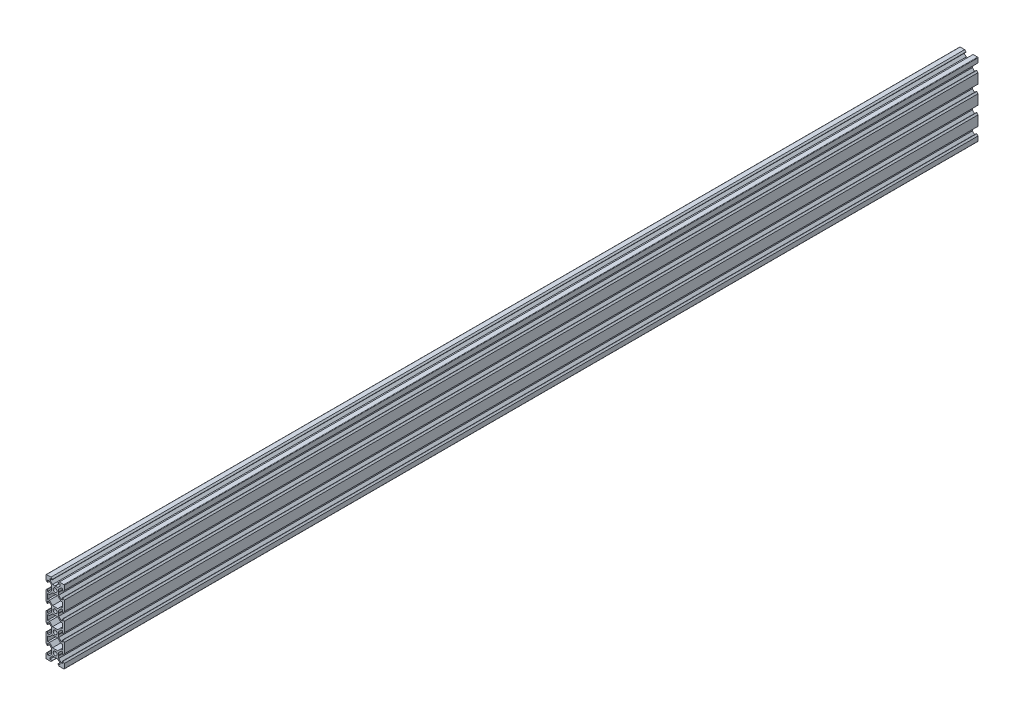
from build123d import *

# Parameters (mm, degrees)
SKETCH1_R           = 2.1
BOSS_EXTRUDE1_DEPTH = 1000


with BuildPart() as part:
    # Sketch1 → Boss-Extrude1 (new body)
    with BuildSketch(Plane.XY):
        with BuildLine():
            Line((4.58, -40), (9.5, -40))
            ThreePointArc((9.5, -40), (9.853553391, -39.853553391), (10, -39.5))
            Line((10, -39.5), (10, -34.58))
            Line((10, -34.58), (8.545, -33.125))
            Line((8.545, -33.125), (8.2, -33.125))
            Line((8.2, -33.125), (8.2, -35.5))
            Line((8.2, -35.5), (6.560660172, -35.5))
            Line((6.560660172, -35.5), (3.9, -32.839339828))
            Line((3.9, -32.839339828), (3.9, -30.21))
            Line((3.9, -30.21), (3.69, -30))
            Line((3.69, -30), (3.9, -29.79))
            Line((3.9, -29.79), (3.9, -27.160660172))
            Line((3.9, -27.160660172), (6.560660172, -24.5))
            Line((6.560660172, -24.5), (8.2, -24.5))
            Line((8.2, -24.5), (8.2, -26.875))
            Line((8.2, -26.875), (8.545, -26.875))
            Line((8.545, -26.875), (10, -25.42))
            Line((10, -25.42), (10, -14.58))
            Line((10, -14.58), (8.545, -13.125))
            Line((8.545, -13.125), (8.2, -13.125))
            Line((8.2, -13.125), (8.2, -15.5))
            Line((8.2, -15.5), (6.560660172, -15.5))
            Line((6.560660172, -15.5), (3.9, -12.839339828))
            Line((3.9, -12.839339828), (3.9, -10.21))
            Line((3.9, -10.21), (3.69, -10))
            Line((3.69, -10), (3.9, -9.79))
            Line((3.9, -9.79), (3.9, -7.160660172))
            Line((3.9, -7.160660172), (6.560660172, -4.5))
            Line((6.560660172, -4.5), (8.2, -4.5))
            Line((8.2, -4.5), (8.2, -6.875))
            Line((8.2, -6.875), (8.545, -6.875))
            Line((8.545, -6.875), (10, -5.42))
            Line((10, -5.42), (10, 5.42))
            Line((10, 5.42), (8.545, 6.875))
            Line((8.545, 6.875), (8.2, 6.875))
            Line((8.2, 6.875), (8.2, 4.5))
            Line((8.2, 4.5), (6.560660172, 4.5))
            Line((6.560660172, 4.5), (3.9, 7.160660172))
            Line((3.9, 7.160660172), (3.9, 9.79))
            Line((3.9, 9.79), (3.69, 10))
            Line((3.69, 10), (3.9, 10.21))
            Line((3.9, 10.21), (3.9, 12.839339828))
            Line((3.9, 12.839339828), (6.560660172, 15.5))
            Line((6.560660172, 15.5), (8.2, 15.5))
            Line((8.2, 15.5), (8.2, 13.125))
            Line((8.2, 13.125), (8.545, 13.125))
            Line((8.545, 13.125), (10, 14.58))
            Line((10, 14.58), (10, 25.42))
            Line((10, 25.42), (8.545, 26.875))
            Line((8.545, 26.875), (8.2, 26.875))
            Line((8.2, 26.875), (8.2, 24.5))
            Line((8.2, 24.5), (6.560660172, 24.5))
            Line((6.560660172, 24.5), (3.9, 27.160660172))
            Line((3.9, 27.160660172), (3.9, 29.79))
            Line((3.9, 29.79), (3.69, 30))
            Line((3.69, 30), (3.9, 30.21))
            Line((3.9, 30.21), (3.9, 32.839339828))
            Line((3.9, 32.839339828), (6.560660172, 35.5))
            Line((6.560660172, 35.5), (8.2, 35.5))
            Line((8.2, 35.5), (8.2, 33.125))
            Line((8.2, 33.125), (8.545, 33.125))
            Line((8.545, 33.125), (10, 34.58))
            Line((10, 34.58), (10, 39.5))
            ThreePointArc((10, 39.5), (9.853553391, 39.853553391), (9.5, 40))
            Line((9.5, 40), (4.58, 40))
            Line((4.58, 40), (3.125, 38.545))
            Line((3.125, 38.545), (3.125, 38.2))
            Line((3.125, 38.2), (5.5, 38.2))
            Line((5.5, 38.2), (5.5, 36.560660172))
            Line((5.5, 36.560660172), (2.839339828, 33.9))
            Line((2.839339828, 33.9), (0.21, 33.9))
            Line((0.21, 33.9), (0, 33.69))
            Line((0, 33.69), (-0.21, 33.9))
            Line((-0.21, 33.9), (-2.839339828, 33.9))
            Line((-2.839339828, 33.9), (-5.5, 36.560660172))
            Line((-5.5, 36.560660172), (-5.5, 38.2))
            Line((-5.5, 38.2), (-3.125, 38.2))
            Line((-3.125, 38.2), (-3.125, 38.545))
            Line((-3.125, 38.545), (-4.58, 40))
            Line((-4.58, 40), (-9.5, 40))
            ThreePointArc((-9.5, 40), (-9.853553391, 39.853553391), (-10, 39.5))
            Line((-10, 39.5), (-10, 34.58))
            Line((-10, 34.58), (-8.545, 33.125))
            Line((-8.545, 33.125), (-8.2, 33.125))
            Line((-8.2, 33.125), (-8.2, 35.5))
            Line((-8.2, 35.5), (-6.560660172, 35.5))
            Line((-6.560660172, 35.5), (-3.9, 32.839339828))
            Line((-3.9, 32.839339828), (-3.9, 30.21))
            Line((-3.9, 30.21), (-3.69, 30))
            Line((-3.69, 30), (-3.9, 29.79))
            Line((-3.9, 29.79), (-3.9, 27.160660172))
            Line((-3.9, 27.160660172), (-6.560660172, 24.5))
            Line((-6.560660172, 24.5), (-8.2, 24.5))
            Line((-8.2, 24.5), (-8.2, 26.875))
            Line((-8.2, 26.875), (-8.545, 26.875))
            Line((-8.545, 26.875), (-10, 25.42))
            Line((-10, 25.42), (-10, 14.58))
            Line((-10, 14.58), (-8.545, 13.125))
            Line((-8.545, 13.125), (-8.2, 13.125))
            Line((-8.2, 13.125), (-8.2, 15.5))
            Line((-8.2, 15.5), (-6.560660172, 15.5))
            Line((-6.560660172, 15.5), (-3.9, 12.839339828))
            Line((-3.9, 12.839339828), (-3.9, 10.21))
            Line((-3.9, 10.21), (-3.69, 10))
            Line((-3.69, 10), (-3.9, 9.79))
            Line((-3.9, 9.79), (-3.9, 7.160660172))
            Line((-3.9, 7.160660172), (-6.560660172, 4.5))
            Line((-6.560660172, 4.5), (-8.2, 4.5))
            Line((-8.2, 4.5), (-8.2, 6.875))
            Line((-8.2, 6.875), (-8.545, 6.875))
            Line((-8.545, 6.875), (-10, 5.42))
            Line((-10, 5.42), (-10, -5.42))
            Line((-10, -5.42), (-8.545, -6.875))
            Line((-8.545, -6.875), (-8.2, -6.875))
            Line((-8.2, -6.875), (-8.2, -4.5))
            Line((-8.2, -4.5), (-6.560660172, -4.5))
            Line((-6.560660172, -4.5), (-3.9, -7.160660172))
            Line((-3.9, -7.160660172), (-3.9, -9.79))
            Line((-3.9, -9.79), (-3.69, -10))
            Line((-3.69, -10), (-3.9, -10.21))
            Line((-3.9, -10.21), (-3.9, -12.839339828))
            Line((-3.9, -12.839339828), (-6.560660172, -15.5))
            Line((-6.560660172, -15.5), (-8.2, -15.5))
            Line((-8.2, -15.5), (-8.2, -13.125))
            Line((-8.2, -13.125), (-8.545, -13.125))
            Line((-8.545, -13.125), (-10, -14.58))
            Line((-10, -14.58), (-10, -25.42))
            Line((-10, -25.42), (-8.545, -26.875))
            Line((-8.545, -26.875), (-8.2, -26.875))
            Line((-8.2, -26.875), (-8.2, -24.5))
            Line((-8.2, -24.5), (-6.560660172, -24.5))
            Line((-6.560660172, -24.5), (-3.9, -27.160660172))
            Line((-3.9, -27.160660172), (-3.9, -29.79))
            Line((-3.9, -29.79), (-3.69, -30))
            Line((-3.69, -30), (-3.9, -30.21))
            Line((-3.9, -30.21), (-3.9, -32.839339828))
            Line((-3.9, -32.839339828), (-6.560660172, -35.5))
            Line((-6.560660172, -35.5), (-8.2, -35.5))
            Line((-8.2, -35.5), (-8.2, -33.125))
            Line((-8.2, -33.125), (-8.545, -33.125))
            Line((-8.545, -33.125), (-10, -34.58))
            Line((-10, -34.58), (-10, -39.5))
            ThreePointArc((-10, -39.5), (-9.853553391, -39.853553391), (-9.5, -40))
            Line((-9.5, -40), (-4.58, -40))
            Line((-4.58, -40), (-3.125, -38.545))
            Line((-3.125, -38.545), (-3.125, -38.2))
            Line((-3.125, -38.2), (-5.5, -38.2))
            Line((-5.5, -38.2), (-5.5, -36.560660172))
            Line((-5.5, -36.560660172), (-2.839339828, -33.9))
            Line((-2.839339828, -33.9), (-0.21, -33.9))
            Line((-0.21, -33.9), (0, -33.69))
            Line((0, -33.69), (0.21, -33.9))
            Line((0.21, -33.9), (2.839339828, -33.9))
            Line((2.839339828, -33.9), (5.5, -36.560660172))
            Line((5.5, -36.560660172), (5.5, -38.2))
            Line((5.5, -38.2), (3.125, -38.2))
            Line((3.125, -38.2), (3.125, -38.545))
            Line((3.125, -38.545), (4.58, -40))
        make_face()
        with Locations((0, -30)):
            Circle(SKETCH1_R, mode=Mode.SUBTRACT)
        Polygon((-6.239339828, -22.7), (-8.2, -22.7), (-8.2, -17.3), (-6.239339828, -17.3), (-2.839339828, -13.9), (2.839339828, -13.9), (6.239339828, -17.3), (8.2, -17.3), (8.2, -22.7), (6.239339828, -22.7), (2.839339828, -26.1), (-2.839339828, -26.1), align=None, mode=Mode.SUBTRACT)
        with Locations((0, -10)):
            Circle(SKETCH1_R, mode=Mode.SUBTRACT)
        Polygon((-6.239339828, -2.7), (-8.2, -2.7), (-8.2, 2.7), (-6.239339828, 2.7), (-2.839339828, 6.1), (2.839339828, 6.1), (6.239339828, 2.7), (8.2, 2.7), (8.2, -2.7), (6.239339828, -2.7), (2.839339828, -6.1), (-2.839339828, -6.1), align=None, mode=Mode.SUBTRACT)
        with Locations((0, 10)):
            Circle(SKETCH1_R, mode=Mode.SUBTRACT)
        Polygon((-6.239339828, 17.3), (-8.2, 17.3), (-8.2, 22.7), (-6.239339828, 22.7), (-2.839339828, 26.1), (2.839339828, 26.1), (6.239339828, 22.7), (8.2, 22.7), (8.2, 17.3), (6.239339828, 17.3), (2.839339828, 13.9), (-2.839339828, 13.9), align=None, mode=Mode.SUBTRACT)
        with Locations((0, 30)):
            Circle(SKETCH1_R, mode=Mode.SUBTRACT)
    extrude(amount=BOSS_EXTRUDE1_DEPTH)


solid = part.part
